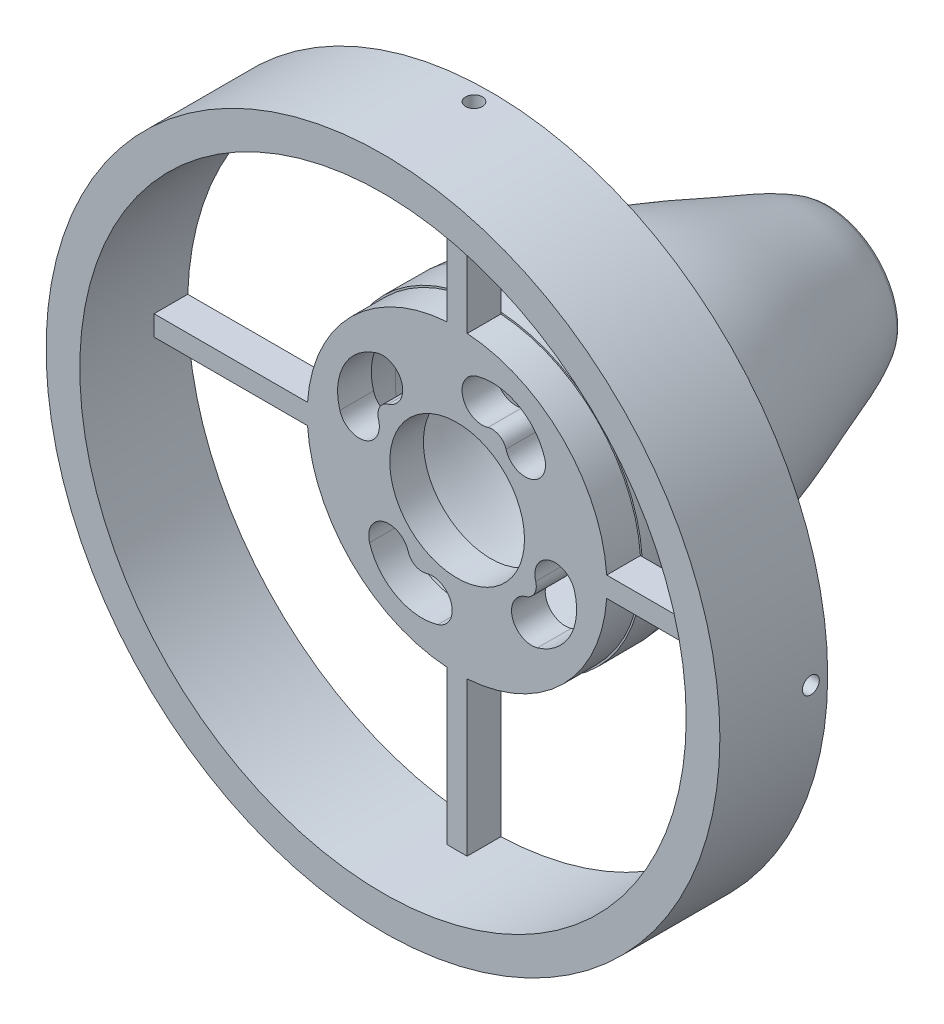
from build123d import *

# Parameters (mm, degrees)
SKETCH4_R           = 50
SKETCH4_R_2         = 45
BOSS_EXTRUDE2_DEPTH = 2.5
SKETCH6_R           = 22.25
SKETCH6_R_2         = 10
BOSS_EXTRUDE3_DEPTH = 2.5
BOSS_EXTRUDE4_DEPTH = 2.5
CIRPATTERN1_COUNT   = 4
CUT_EXTRUDE2_DEPTH  = 20
SKETCH19_R          = 1.25
CUT_EXTRUDE3_DEPTH  = 2.5
CIRPATTERN2_COUNT   = 4
SKETCH20_R          = 50
SKETCH20_R_2        = 45
BOSS_EXTRUDE5_DEPTH = 11


with BuildPart() as part:
    # Sketch4 → Boss-Extrude2 (new body, symmetric)
    with BuildSketch(Plane.XY):
        Circle(SKETCH4_R)
        Circle(SKETCH4_R_2, mode=Mode.SUBTRACT)
    extrude(amount=BOSS_EXTRUDE2_DEPTH, both=True)



with BuildPart() as body_2:
    # Sketch6 → Boss-Extrude3 (new body, symmetric)
    with BuildSketch(Plane.XY):
        Circle(SKETCH6_R)
        Circle(SKETCH6_R_2, mode=Mode.SUBTRACT)
    extrude(amount=BOSS_EXTRUDE3_DEPTH, both=True)


with BuildPart() as part_1:
    add(part.part)

    add(body_2.part)  # Boss-Extrude4 merges body 2
    # Sketch7 → Boss-Extrude4 (add, symmetric)
    with BuildSketch(Plane.XY):
        with BuildLine():
            Line((1.5, 22.173723668), (1.5, 44.974993052))
            ThreePointArc((1.5, 44.974993052), (0, 45), (-1.5, 44.974993052))
            Line((-1.5, 44.974993052), (-1.5, 22.173723668))
            ThreePointArc((-1.5, 22.173723668), (0, 22.224401484), (1.5, 22.173723668))
        make_face()
    boss_extrude4 = extrude(amount=BOSS_EXTRUDE4_DEPTH, both=True)

    # CirPattern1: Boss-Extrude4 ×4 about axis
    cirpattern1_axis = Axis((0, 0, 0), (0, 0, 1))
    for i in range(1, CIRPATTERN1_COUNT):
        add(boss_extrude4.rotate(cirpattern1_axis, i * 360 / CIRPATTERN1_COUNT))

    # Sketch16 → Revolve5 (revolve)
    with BuildSketch(Plane(origin=(0, 0, 0), x_dir=(0, 0, -1), z_dir=(1, 0, 0))):
        with BuildLine():
            Line((2.5, 22.5), (2.5, 20))
            Line((2.5, 20), (8.319227557, 20))
            add(Edge.make_bspline(
                [(8.319227557, 20), (11.123254562, 19.6727407), (15.973153481, 19.619040378), (22.945159124, 18.263658856), (29.398925624, 16.810806242), (36.513582053, 14.385022759), (43.601684551, 11.54818751), (48.61668349, 9.827339582), (50.700170198, 8.605167266)],
                knots=[0, 0, 0, 0, 0.1918853, 0.327499488, 0.481339331, 0.640782173, 0.837003533, 1, 1, 1, 1], degree=3))
            add(Edge.make_bspline(
                [(50.700170198, 8.605167266), (51.227102493, 8.224080677), (51.754034788, 7.842994089)],
                knots=[0, 0, 0, 1, 1, 1], degree=2))
            Line((51.754034788, 7.842994089), (52.5, 7.303499091))
            Line((52.5, 7.303499091), (52.5, 10.388790167))
            add(Edge.make_bspline(
                [(52.068285629, 10.701013498), (52.122249925, 10.661985582), (52.284142815, 10.544901832), (52.446035704, 10.427818083), (52.5, 10.388790167)],
                knots=[-0.091980981, -0.091980981, -0.091980981, 0.010431221, 0.215255624, 0.317667825, 0.317667825, 0.317667825], degree=2))
            add(Edge.make_bspline(
                [(8.464622197, 22.5), (9.346604646, 22.397063417), (11.091341923, 22.245478983), (13.864723915, 22.08493702), (16.750982068, 21.863282745), (19.67100668, 21.437998985), (22.472128979, 20.890581106), (25.220298474, 20.307886272), (27.995926722, 19.661513734), (31.709227942, 18.654015601), (35.320256891, 17.428854793), (38.839343196, 16.113628139), (41.44099355, 15.113187926), (44.015827232, 14.123528369), (46.587421441, 13.193671921), (48.868261591, 12.319589328), (50.476081329, 11.570913159), (51.283275743, 11.147887794), (51.680089744, 10.926618218), (51.915375523, 10.790958684), (52.015905313, 10.731739767), (52.068285629, 10.701013498)],
                knots=[-0.003294191, -0.003294191, -0.003294191, -0.003294191, 0.059579874, 0.122453939, 0.185328004, 0.248202069, 0.311076134, 0.373950199, 0.436824265, 0.49969833, 0.62544646, 0.688320525, 0.75119459, 0.814068655, 0.87694272, 0.939816785, 0.971253818, 0.986972334, 0.994831592, 0.998761221, 1.00269085, 1.00269085, 1.00269085, 1.00269085], degree=3))
            Line((8.464622197, 22.5), (7.5, 22.5))
            Line((7.5, 22.5), (5, 22.5))
            Line((5, 22.5), (2.5, 22.5))
        make_face()
    revolve(axis=Axis((0, 0, -2.5), (0, 0, -1)))

    # Sketch17 → Cut-Extrude2 (cut)
    with BuildSketch(Plane.XY.offset(2.5)):
        with BuildLine():
            ThreePointArc((12.992330947, 11.923401399), (9.06375587, 16.758610598), (2.86682458, 17.399697733))
            ThreePointArc((2.86682458, 17.399697733), (0.852954159, 13.676112204), (4.576539687, 11.662241783))
            ThreePointArc((4.576539687, 11.662241783), (6.215713007, 11.492665443), (7.254874997, 10.213686293))
            ThreePointArc((7.254874997, 10.213686293), (10.978460525, 8.199815871), (12.992330947, 11.923401399))
        make_face()
        with BuildLine():
            ThreePointArc((11.923401399, -12.992330947), (16.758610598, -9.06375587), (17.399697733, -2.86682458))
            ThreePointArc((17.399697733, -2.86682458), (13.676112204, -0.852954159), (11.662241783, -4.576539687))
            ThreePointArc((11.662241783, -4.576539687), (11.492665443, -6.215713007), (10.213686293, -7.254874997))
            ThreePointArc((10.213686293, -7.254874997), (8.199815871, -10.978460525), (11.923401399, -12.992330947))
        make_face()
        with BuildLine():
            ThreePointArc((-12.992330947, -11.923401399), (-9.06375587, -16.758610598), (-2.86682458, -17.399697733))
            ThreePointArc((-2.86682458, -17.399697733), (-0.852954159, -13.676112204), (-4.576539687, -11.662241783))
            ThreePointArc((-4.576539687, -11.662241783), (-6.215713007, -11.492665443), (-7.254874997, -10.213686293))
            ThreePointArc((-7.254874997, -10.213686293), (-10.978460525, -8.199815871), (-12.992330947, -11.923401399))
        make_face()
        with BuildLine():
            ThreePointArc((-11.923401399, 12.992330947), (-16.758610598, 9.06375587), (-17.399697733, 2.86682458))
            ThreePointArc((-17.399697733, 2.86682458), (-13.676112204, 0.852954159), (-11.662241783, 4.576539687))
            ThreePointArc((-11.662241783, 4.576539687), (-11.492665443, 6.215713007), (-10.213686293, 7.254874997))
            ThreePointArc((-10.213686293, 7.254874997), (-8.199815871, 10.978460525), (-11.923401399, 12.992330947))
        make_face()
    extrude(amount=-CUT_EXTRUDE2_DEPTH, mode=Mode.SUBTRACT)

    # Sketch19 → Cut-Extrude3 (cut, symmetric)
    with BuildSketch(Plane(origin=(0, 47.5, 0), x_dir=(1, 0, 0), z_dir=(0, 1, 0))):
        Circle(SKETCH19_R)
    cut_extrude3 = extrude(amount=CUT_EXTRUDE3_DEPTH, both=True, mode=Mode.SUBTRACT)

    # CirPattern2: Cut-Extrude3 ×4 about axis
    cirpattern2_axis = Axis((0, 0, 0), (0, 0, 1))
    for i in range(1, CIRPATTERN2_COUNT):
        add(cut_extrude3.rotate(cirpattern2_axis, i * 360 / CIRPATTERN2_COUNT), mode=Mode.SUBTRACT)

    # Sketch20 → Boss-Extrude5 (add)
    with BuildSketch(Plane.XY.offset(2.5)):
        Circle(SKETCH20_R)
        Circle(SKETCH20_R_2, mode=Mode.SUBTRACT)
    extrude(amount=BOSS_EXTRUDE5_DEPTH)


solid = part_1.part
